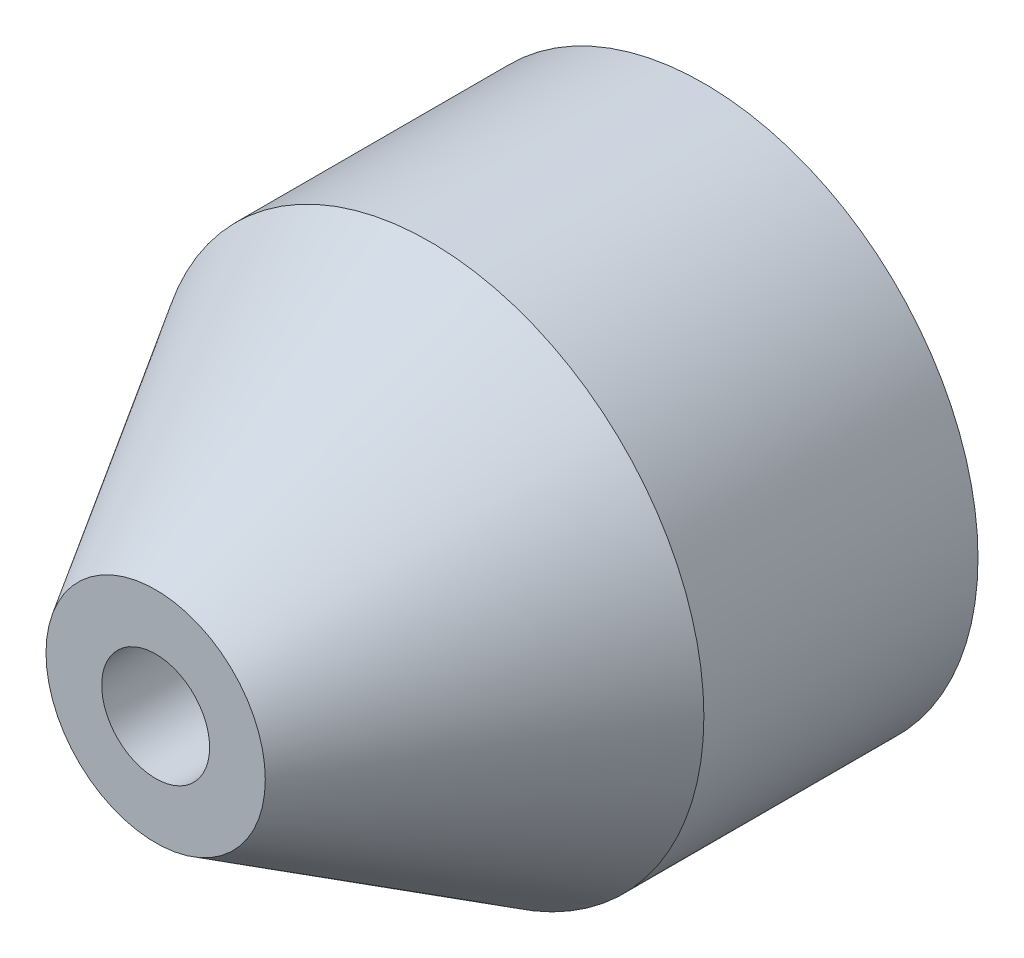
from build123d import *

# Parameters (mm, degrees)
SKETCH1_R                 = 6.35
BOSS_EXTRUDE1_DEPTH       = 12.7
M3X0_5_TAPPED_HOLE1_D     = 2.5
F_6_32_TAPPED_HOLE1_D     = 2.7051
F_6_32_TAPPED_HOLE1_DEPTH = 9.398
F_6_32_TAPPED_HOLE1_TIP   = 0.81269403
CHAMFER1_SIZE             = 6.35
CHAMFER1_SIZE2            = 3.81


with BuildPart() as part:
    # Sketch1 → Boss-Extrude1 (new body)
    with BuildSketch(Plane.XY):
        Circle(SKETCH1_R)
    extrude(amount=BOSS_EXTRUDE1_DEPTH)

    # M3x0.5 Tapped Hole1 (through all)
    with Locations(Plane.XY.offset(12.7)):
        with Locations((0, 0)):
            Hole(M3X0_5_TAPPED_HOLE1_D / 2)

    # #6-32 Tapped Hole1
    with Locations(Plane(origin=(0, 0, 0), x_dir=(-1, 0, 0), z_dir=(0, 0, -1))):
        with Locations((0, 0)):
            Hole(F_6_32_TAPPED_HOLE1_D / 2, depth=F_6_32_TAPPED_HOLE1_DEPTH)
            with Locations((0, 0, -(F_6_32_TAPPED_HOLE1_DEPTH + F_6_32_TAPPED_HOLE1_TIP / 2))):  # 118° drill point
                Cone(0, F_6_32_TAPPED_HOLE1_D / 2, F_6_32_TAPPED_HOLE1_TIP, mode=Mode.SUBTRACT)

    # Chamfer1
    chamfer1_edges = [part.edges().sort_by_distance(p)[0] for p in [
        (-6.35, 0, 12.7),
    ]]
    chamfer1_side = [part.faces().sort_by_distance(p)[0] for p in [
        (-6.35, 0, 6.35),
    ]]
    chamfer(chamfer1_edges, length=CHAMFER1_SIZE, length2=CHAMFER1_SIZE2, reference=chamfer1_side[0])


solid = part.part
